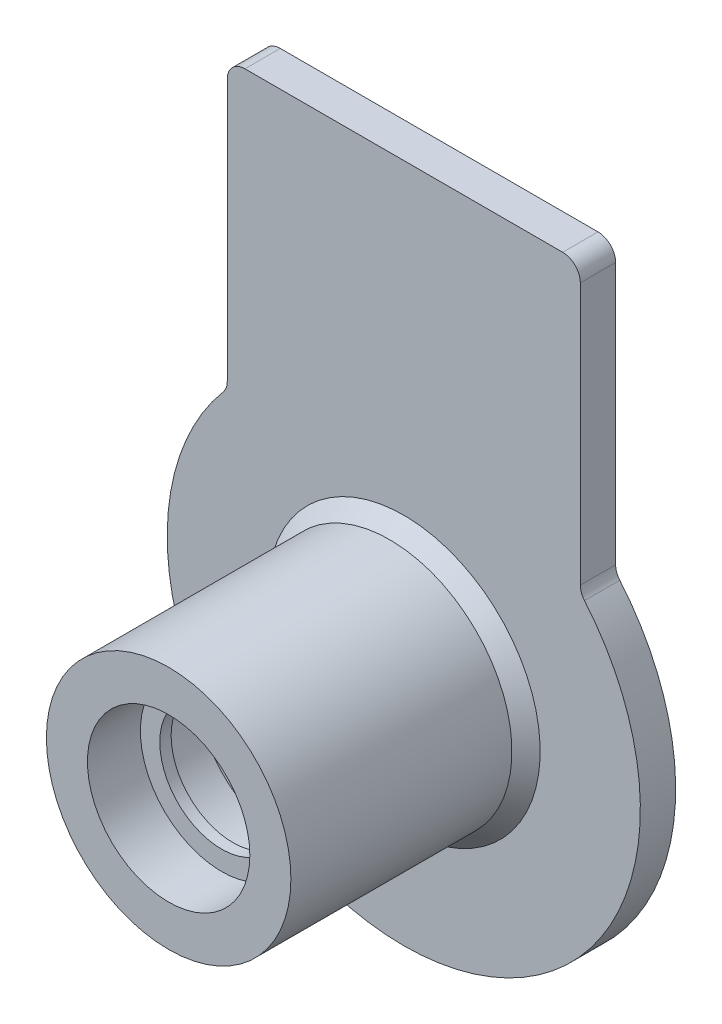
from build123d import *

# Parameters (mm, degrees)
BOSS_EXTRUDE1_DEPTH = 2
FILLET2_R           = 1
CHAMFER1_SIZE       = 0.8
SKETCH4_R           = 6.925
SKETCH4_R_2         = 4.6
BOSS_EXTRUDE2_DEPTH = 3


with BuildPart() as part:
    # Sketch2 → Revolve1 (revolve)
    with BuildSketch(Plane(origin=(0, 0, 0), x_dir=(1, 0, 0), z_dir=(0, 1, 0))):
        Polygon((-3.5, -12.32), (-3.5, -11.68), (-4.925, -11.2), (-4.925, -8.7), (-3.45, -8.7), (-3.45, -7.5), (-5, -7.5), (-5, 0), (-13.4, 0), (-13.4, -2), (-6.925, -2), (-6.925, -12.32), align=None)
    revolve(axis=Axis((0, 0, 0), (0, 0, 1)))

    # Sketch3 → Boss-Extrude1 (add)
    with BuildSketch(Plane.XY.offset(2)):
        with BuildLine():
            Line((10, 8.919641248), (10, 25.121576202))
            Line((10, 25.121576202), (-10, 25.121576202))
            Line((-10, 25.121576202), (-10, 8.919641248))
            ThreePointArc((-10, 8.919641248), (0, 13.4), (10, 8.919641248))
        make_face()
    extrude(amount=-BOSS_EXTRUDE1_DEPTH)

    # Fillet2
    fillet2_edges = [part.edges().sort_by_distance(p)[0] for p in [
        (10, 25.121576202, 1),
        (-10, 25.121576202, 1),
        (-10, 8.919641248, 1),
        (10, 8.919641248, 1),
    ]]
    fillet(fillet2_edges, radius=FILLET2_R)

    # Chamfer1
    chamfer1_edges = [part.edges().sort_by_distance(p)[0] for p in [
        (6.925, 0, 2),
    ]]
    chamfer(chamfer1_edges, length=CHAMFER1_SIZE)

    # Sketch4 → Boss-Extrude2 (add)
    with BuildSketch(Plane.XY.offset(12.32)):
        with Locations(Location((0, 0, 0), (0, 0, 180))):
            Circle(SKETCH4_R)
        Circle(SKETCH4_R_2, mode=Mode.SUBTRACT)
    extrude(amount=BOSS_EXTRUDE2_DEPTH)


solid = part.part
